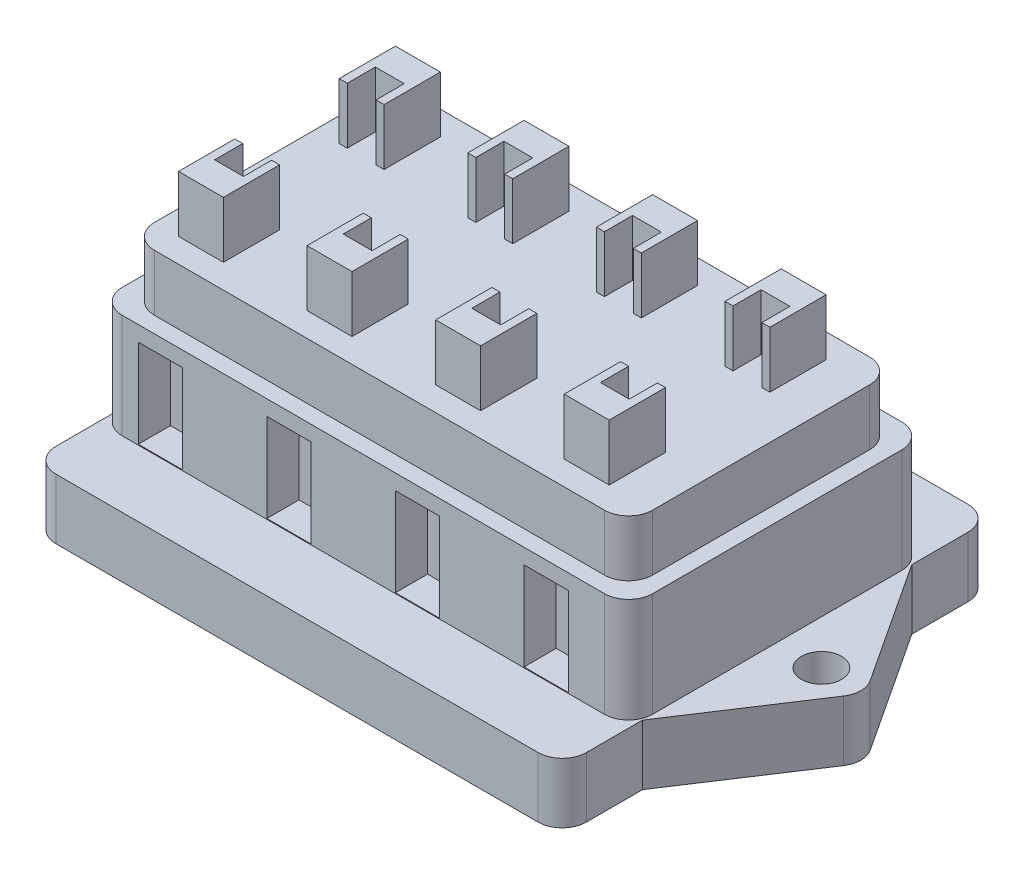
from build123d import *

# Parameters (mm, degrees)
SKETCH1_R               = 2.5
BOSS_EXTRUDE1_DEPTH     = 7.5
BOSS_EXTRUDE2_DEPTH     = 20
BOSS_EXTRUDE3_DEPTH     = 7
CUT_EXTRUDE_THIN1_DEPTH = 7
SKETCH5_W               = 5.5
SKETCH5_H               = 11
CUT_EXTRUDE2_DEPTH      = 4
SKETCH6_W               = 5.5
SKETCH6_H               = 11
CUT_EXTRUDE3_DEPTH      = 4


with BuildPart() as part:
    # Sketch1 → Boss-Extrude1 (new body)
    with BuildSketch(Plane(origin=(0, 0, 0), x_dir=(1, 0, 0), z_dir=(0, 1, 0))):
        with BuildLine():
            Line((33, 16.75), (42.918528102, 1.646786754))
            ThreePointArc((42.918528102, 1.646786754), (43.410920998, 0), (42.918528102, -1.646786754))
            Line((42.918528102, -1.646786754), (33, -16.75))
            Line((33, -16.75), (33, -23.75))
            ThreePointArc((33, -23.75), (32.121320344, -25.871320344), (30, -26.75))
            Line((30, -26.75), (-30, -26.75))
            ThreePointArc((-30, -26.75), (-32.121320344, -25.871320344), (-33, -23.75))
            Line((-33, -23.75), (-33, -16.75))
            Line((-33, -16.75), (-42.918528102, -1.646786754))
            ThreePointArc((-42.918528102, -1.646786754), (-43.410920998, 0), (-42.918528102, 1.646786754))
            Line((-42.918528102, 1.646786754), (-33, 16.75))
            Line((-33, 16.75), (-33, 23.75))
            ThreePointArc((-33, 23.75), (-32.121320344, 25.871320344), (-30, 26.75))
            Line((-30, 26.75), (30, 26.75))
            ThreePointArc((30, 26.75), (32.121320344, 25.871320344), (33, 23.75))
            Line((33, 23.75), (33, 16.75))
        make_face()
        with Locations((38.5, 0)):
            Circle(SKETCH1_R, mode=Mode.SUBTRACT)
        with Locations((-38.5, 0)):
            Circle(SKETCH1_R, mode=Mode.SUBTRACT)
    extrude(amount=BOSS_EXTRUDE1_DEPTH)

    # Sketch2 → Boss-Extrude2 (add)
    with BuildSketch(Plane(origin=(0, 7.5, 0), x_dir=(1, 0, 0), z_dir=(0, 1, 0))):
        with BuildLine():
            Line((-30, 18.5), (30, 18.5))
            ThreePointArc((30, 18.5), (32.121320344, 17.621320344), (33, 15.5))
            Line((33, 15.5), (33, -15.5))
            ThreePointArc((33, -15.5), (32.121320344, -17.621320344), (30, -18.5))
            Line((30, -18.5), (-30, -18.5))
            ThreePointArc((-30, -18.5), (-32.121320344, -17.621320344), (-33, -15.5))
            Line((-33, -15.5), (-33, 15.5))
            ThreePointArc((-33, 15.5), (-32.121320344, 17.621320344), (-30, 18.5))
        make_face()
    extrude(amount=BOSS_EXTRUDE2_DEPTH)

    # Sketch3 → Boss-Extrude3 (add)
    with BuildSketch(Plane(origin=(0, 27.5, 0), x_dir=(1, 0, 0), z_dir=(0, 1, 0))):
        Polygon((-28, 13.5), (-22.4116483, 13.5), (-22.4116483, 6.5), (-23.4116483, 6.5), (-23.4116483, 10), (-27, 10), (-27, 6.5), (-28, 6.5), align=None)
        Polygon((-12, 13.5), (-6.4116483, 13.5), (-6.4116483, 6.5), (-7.4116483, 6.5), (-7.4116483, 10), (-11, 10), (-11, 6.5), (-12, 6.5), align=None)
        Polygon((4, 13.5), (9.5883517, 13.5), (9.5883517, 6.5), (8.5883517, 6.5), (8.5883517, 10), (5, 10), (5, 6.5), (4, 6.5), align=None)
        Polygon((20, 13.5), (25.5883517, 13.5), (25.5883517, 6.5), (24.5883517, 6.5), (24.5883517, 10), (21, 10), (21, 6.5), (20, 6.5), align=None)
        Polygon((-12, -6.5), (-11, -6.5), (-11, -10), (-7.4116483, -10), (-7.4116483, -6.5), (-6.4116483, -6.5), (-6.4116483, -13.5), (-12, -13.5), align=None)
        Polygon((4, -6.5), (5, -6.5), (5, -10), (8.5883517, -10), (8.5883517, -6.5), (9.5883517, -6.5), (9.5883517, -13.5), (4, -13.5), align=None)
        Polygon((20, -6.5), (21, -6.5), (21, -10), (24.5883517, -10), (24.5883517, -6.5), (25.5883517, -6.5), (25.5883517, -13.5), (20, -13.5), align=None)
        Polygon((-28, -6.5), (-27, -6.5), (-27, -10), (-23.4116483, -10), (-23.4116483, -6.5), (-22.4116483, -6.5), (-22.4116483, -13.5), (-28, -13.5), align=None)
    extrude(amount=BOSS_EXTRUDE3_DEPTH)

    # Sketch4 → Cut-Extrude-Thin1 (cut)
    with BuildSketch(Plane(origin=(0, 27.5, 0), x_dir=(1, 0, 0), z_dir=(0, 1, 0))):
        with BuildLine():
            Line((-28, 19.5), (28, 19.5))
            ThreePointArc((28, 19.5), (32.242640687, 17.742640687), (34, 13.5))
            Line((34, 13.5), (34, -13.5))
            ThreePointArc((34, -13.5), (32.242640687, -17.742640687), (28, -19.5))
            Line((28, -19.5), (-28, -19.5))
            ThreePointArc((-28, -19.5), (-32.242640687, -17.742640687), (-34, -13.5))
            Line((-34, -13.5), (-34, 13.5))
            ThreePointArc((-34, 13.5), (-32.242640687, 17.742640687), (-28, 19.5))
        make_face()
        with BuildLine():
            Line((-28, 16.5), (28, 16.5))
            ThreePointArc((28, 16.5), (30.121320344, 15.621320344), (31, 13.5))
            Line((31, 13.5), (31, -13.5))
            ThreePointArc((31, -13.5), (30.121320344, -15.621320344), (28, -16.5))
            Line((28, -16.5), (-28, -16.5))
            ThreePointArc((-28, -16.5), (-30.121320344, -15.621320344), (-31, -13.5))
            Line((-31, -13.5), (-31, 13.5))
            ThreePointArc((-31, 13.5), (-30.121320344, 15.621320344), (-28, 16.5))
        make_face(mode=Mode.SUBTRACT)
    extrude(amount=-CUT_EXTRUDE_THIN1_DEPTH, mode=Mode.SUBTRACT)

    # Sketch5 → Cut-Extrude2 (cut)
    with BuildSketch(Plane.XY.offset(18.5)):
        with Locations((-25.25, 13.1)):
            Rectangle(SKETCH5_W, SKETCH5_H)
        with Locations((-9.25, 13.1)):
            Rectangle(SKETCH5_W, SKETCH5_H)
        with Locations((6.75, 13.1)):
            Rectangle(SKETCH5_W, SKETCH5_H)
        with Locations((22.75, 13.1)):
            Rectangle(SKETCH5_W, SKETCH5_H)
    extrude(amount=-CUT_EXTRUDE2_DEPTH, mode=Mode.SUBTRACT)

    # Sketch6 → Cut-Extrude3 (cut)
    with BuildSketch(Plane(origin=(0, 0, -18.5), x_dir=(-1, 0, 0), z_dir=(0, 0, -1))):
        with Locations((-23.25, 13)):
            Rectangle(SKETCH6_W, SKETCH6_H)
        with Locations((-7.25, 13)):
            Rectangle(SKETCH6_W, SKETCH6_H)
        with Locations((8.75, 13)):
            Rectangle(SKETCH6_W, SKETCH6_H)
        with Locations((24.75, 13)):
            Rectangle(SKETCH6_W, SKETCH6_H)
    extrude(amount=-CUT_EXTRUDE3_DEPTH, mode=Mode.SUBTRACT)


solid = part.part
